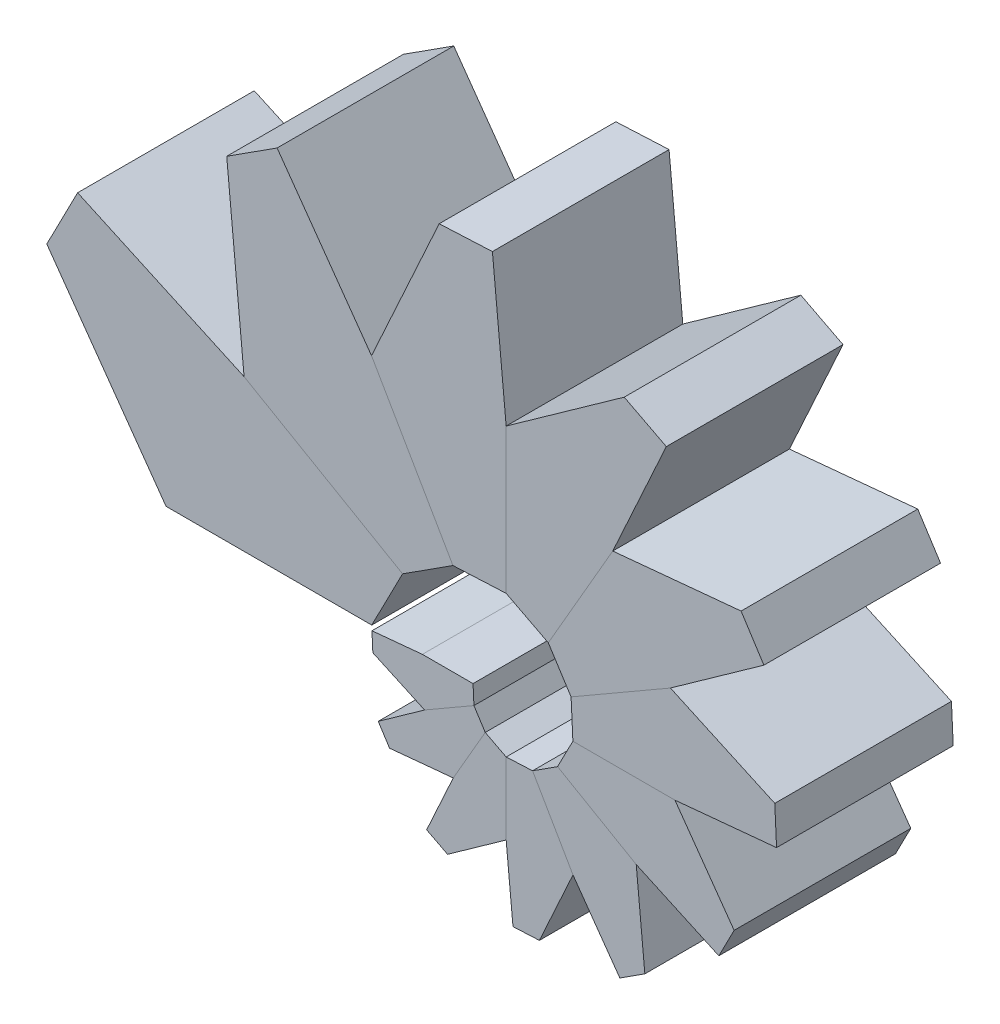
from build123d import *

# Parameters (mm, degrees)
BOSS_EXTRU_1_DEPTH  = 7.5
BOSS_EXTRU_3_DEPTH  = 7.5
BOSS_EXTRU_4_DEPTH  = 7.5
BOSS_EXTRU_5_DEPTH  = 7.5
BOSS_EXTRU_6_DEPTH  = 7.5
BOSS_EXTRU_7_DEPTH  = 7.5
BOSS_EXTRU_8_DEPTH  = 7.5
BOSS_EXTRU_9_DEPTH  = 7.5
BOSS_EXTRU_10_DEPTH = 7.5
BOSS_EXTRU_11_DEPTH = 7.5
BOSS_EXTRU_12_DEPTH = 7.5
BOSS_EXTRU_13_DEPTH = 7.5


with BuildPart() as part:
    # Esquisse20 → Boss.-Extru.1 (new body, symmetric)
    with BuildSketch(Plane.XY):
        Polygon((-10.643517195, 0), (-6.341984433, 0), (-6.266871728, -1.579960424), (-10.453473573, -3.997096126), align=None)
    extrude(amount=BOSS_EXTRU_1_DEPTH, both=True)

    # Symétrie1: part across plane


with BuildPart() as body_2:
    # Esquisse21 → Boss.-Extru.3 (new body, symmetric)
    with BuildSketch(Plane.XY):
        Polygon((-5.305934527, -3.075489216), (-8.022456613, -7.780643489), (-3.5303, -10.097081162), (-3.5303, -3.991068195), align=None)
    extrude(amount=BOSS_EXTRU_3_DEPTH, both=True)

    # Symétrie3: body 2 across plane


with BuildPart() as body_3:
    # Esquisse22 → Boss.-Extru.4 (new body, symmetric)
    with BuildSketch(Plane.XY):
        Polygon((-6.266871728, -1.579960424), (-5.305934527, -3.075489216), (-8.022456613, -7.780643489), (-10.453473573, -3.997096126), align=None)
    extrude(amount=BOSS_EXTRU_4_DEPTH, both=True)

    # Symétrie2: body 3 across plane


with BuildPart() as body_4:
    # Esquisse23 → Boss.-Extru.5 (new body, symmetric)
    with BuildSketch(Plane.XY):
        Polygon((-3.5303, -3.991068195), (-1.287686712, -3.884320156), (2.143508969, -9.827325407), (-3.5303, -10.097081162), align=None)
    extrude(amount=BOSS_EXTRU_5_DEPTH, both=True)

    # Symétrie4: body 4 across plane


with BuildPart() as body_5:
    # Esquisse24 → Boss.-Extru.6 (new body, symmetric)
    with BuildSketch(Plane.XY):
        Polygon((-1.287686712, -3.884320156), (0.835256513, -2.520455228), (7.51412158, -6.376499772), (2.143508969, -9.827325407), align=None)
    extrude(amount=BOSS_EXTRU_6_DEPTH, both=True)

    # Symétrie5: body 5 across plane


with BuildPart() as body_6:
    # Esquisse25 → Boss.-Extru.7 (new body, symmetric)
    with BuildSketch(Plane.XY):
        Polygon((7.51412158, -6.376499772), (10.80205889, 0), (2.134947016, 0), (0.835256513, -2.520455228), align=None)
    extrude(amount=BOSS_EXTRU_7_DEPTH, both=True)

    # Symétrie6: body 6 across plane


with BuildPart() as body_7:
    # Esquisse26 → Boss.-Extru.8 (new body, symmetric)
    with BuildSketch(Plane.XY):
        Polygon((10.80205889, 0), (2.134947016, 0), (1.983545978, 3.18342046), (10.419255773, 8.053779781), align=None)
    extrude(amount=BOSS_EXTRU_8_DEPTH, both=True)

    # Symétrie7: body 7 across plane


with BuildPart() as body_8:
    # Esquisse27 → Boss.-Extru.9 (new body, symmetric)
    with BuildSketch(Plane.XY):
        Polygon((1.983545978, 3.18342046), (10.419255773, 8.053779781), (5.521013255, 15.677334433), (0.047387798, 6.19673704), align=None)
    extrude(amount=BOSS_EXTRU_9_DEPTH, both=True)

    # Symétrie8: body 8 across plane


with BuildPart() as body_9:
    # Esquisse28 → Boss.-Extru.10 (new body, symmetric)
    with BuildSketch(Plane.XY):
        Polygon((0.047387798, 6.19673704), (-3.5303, 8.041696023), (-3.5303, 20.344722064), (5.521013255, 15.677334433), align=None)
    extrude(amount=BOSS_EXTRU_10_DEPTH, both=True)

    # Symétrie9: body 9 across plane


with BuildPart() as body_10:
    # Esquisse29 → Boss.-Extru.11 (new body, symmetric)
    with BuildSketch(Plane.XY):
        Polygon((-3.5303, 8.041696023), (-8.049083477, 7.82676257), (-14.962524173, 19.801193112), (-3.5303, 20.344722064), align=None)
    extrude(amount=BOSS_EXTRU_11_DEPTH, both=True)

    # Symétrie10: body 10 across plane


with BuildPart() as body_11:
    # Esquisse30 → Boss.-Extru.12 (new body, symmetric)
    with BuildSketch(Plane.XY):
        Polygon((-8.049083477, 7.82676257), (-14.962524173, 19.801193112), (-25.783924084, 12.848135855), (-12.326158681, 5.078291377), align=None)
    extrude(amount=BOSS_EXTRU_12_DEPTH, both=True)

    # Symétrie11: body 11 across plane


with BuildPart() as body_12:
    # Esquisse31 → Boss.-Extru.13 (new body, symmetric)
    with BuildSketch(Plane.XY):
        Polygon((-25.783924084, 12.848135855), (-12.326158681, 5.078291377), (-14.945224597, 0), (-32.409116649, 0), align=None)
    extrude(amount=BOSS_EXTRU_13_DEPTH, both=True)

    # Symétrie12: body 12 across plane


with BuildPart() as part_1:
    add(part.part)
    add(part.part.mirror(Plane(origin=(-10.453473573, -3.997096126, 7.5), x_dir=(0, 0, 1), z_dir=(-0.998871629, -0.047491773, 0))))


with BuildPart() as body_3_1:
    add(body_3.part)
    add(body_3.part.mirror(Plane(origin=(-8.022456613, -7.780643489, 7.5), x_dir=(0, 0, 1), z_dir=(0.841306248, 0.540558783, 0))))


with BuildPart() as body_2_1:
    add(body_2.part)
    add(body_2.part.mirror(Plane(origin=(-8.022456613, -7.780643489, 7.5), x_dir=(0, 0, 1), z_dir=(0.458315613, 0.888789513, 0))))


with BuildPart() as body_4_1:
    add(body_4.part)
    add(body_4.part.mirror(Plane(origin=(2.143508969, -9.827325407, 7.5), x_dir=(0, 0, 1), z_dir=(-0.047490388, 0.998871695, 0))))


with BuildPart() as body_5_1:
    add(body_5.part)
    add(body_5.part.mirror(Plane(origin=(7.51412158, -6.376499772, 7.5), x_dir=(0, 0, 1), z_dir=(-0.540567922, 0.841300375, 0))))


with BuildPart() as body_6_1:
    add(body_6.part)
    add(body_6.part.mirror(Plane(origin=(7.51412158, -6.376499772, 7.5), x_dir=(0, 0, 1), z_dir=(-0.888800067, 0.458295147, 0))))


with BuildPart() as body_7_1:
    add(body_7.part)
    add(body_7.part.mirror(Plane(origin=(10.419255773, 8.053779781, 7.5), x_dir=(0, 0, 1), z_dir=(-0.998872319, -0.047477265, 0))))


with BuildPart() as body_8_1:
    add(body_8.part)
    add(body_8.part.mirror(Plane(origin=(10.419255773, 8.053779781, 7.5), x_dir=(0, 0, 1), z_dir=(-0.841309671, -0.540553454, 0))))


with BuildPart() as body_9_1:
    add(body_9.part)
    add(body_9.part.mirror(Plane(origin=(-3.5303, 20.344722064, 7.5), x_dir=(0, 0, 1), z_dir=(-0.458312733, -0.888790999, 0))))


with BuildPart() as body_10_1:
    add(body_10.part)
    add(body_10.part.mirror(Plane(origin=(-14.962524173, 19.801193112, 7.5), x_dir=(0, 0, 1), z_dir=(0.047489945, -0.998871716, 0))))


with BuildPart() as body_11_1:
    add(body_11.part)
    add(body_11.part.mirror(Plane(origin=(-14.962524173, 19.801193112, 7.5), x_dir=(0, 0, 1), z_dir=(0.540561906, -0.841304241, 0))))


with BuildPart() as body_12_1:
    add(body_12.part)
    add(body_12.part.mirror(Plane(origin=(-32.409116649, 0, 7.5), x_dir=(0, 0, 1), z_dir=(0.888792671, -0.45830949, 0))))


solid = Compound([part_1.part, body_3_1.part, body_2_1.part, body_4_1.part, body_5_1.part, body_6_1.part, body_7_1.part, body_8_1.part, body_9_1.part, body_10_1.part, body_11_1.part, body_12_1.part])
